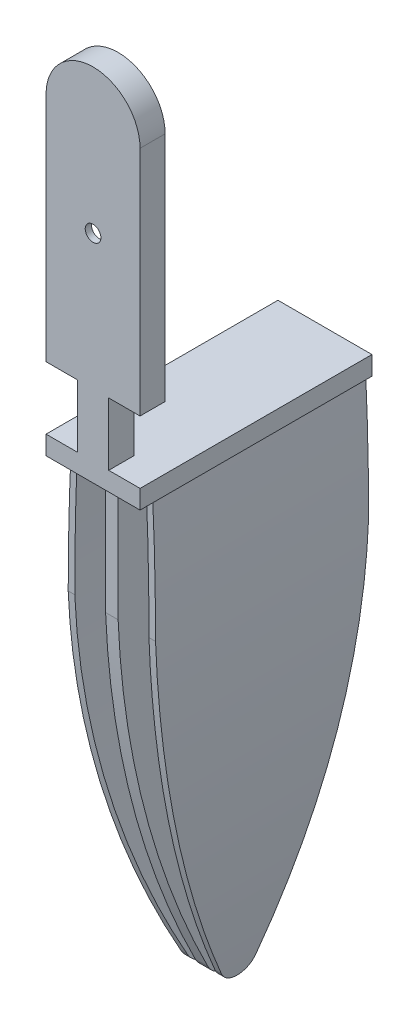
from build123d import *

# Parameters (mm, degrees)
EXTRUDE_1_DEPTH          = 2
EXTRUDE_1_DEPTH_BACK     = 2
EXTRUDE_2_DEPTH          = 7.5
EXTRUDE_2_DEPTH_BACK     = 7.5
SKETCH_6_W               = 37
SKETCH_6_H               = 3
EXTRUDE_4_DEPTH          = 1
EXTRUDE_4_DEPTH_BACK     = 1
FILLET_1_R               = 3
EXTRUDE_8_DEPTH          = 17
EXTRUDE_8_DEPTH_BACK     = 17
CUT_EXTRUDE_3_DEPTH      = 17.5
CUT_EXTRUDE_3_DEPTH_BACK = 17.5
FILLET_7_R               = 3
FILLET_8_R               = 3
FILLET_9_R               = 3
FILLET_10_R              = 3
SKETCH_21_W              = 5
SKETCH_21_H              = 10
CUT_EXTRUDE_4_DEPTH      = 4
CUT_EXTRUDE_5_DEPTH      = 1
CUT_EXTRUDE_5_DEPTH_BACK = 2
SKETCH_23_R              = 1.25
CUT_EXTRUDE_6_DEPTH      = 13


with BuildPart() as part:
    # 草圖1 → 填料-伸長1 (new, two sides: drawn at the far end of the back side and taken through both)
    with BuildSketch(Plane.XY.offset(-EXTRUDE_1_DEPTH_BACK)):
        with BuildLine():
            Line((7.5, 8), (7.5, 55))
            ThreePointArc((7.5, 55), (0, 62.5), (-7.5, 55))
            Line((-7.5, 55), (-7.5, 8))
            Line((-7.5, 8), (7.5, 8))
        make_face()
    extrude(amount=EXTRUDE_1_DEPTH + EXTRUDE_1_DEPTH_BACK)

    # 草圖6 → 填料-伸長2 (add, two sides: drawn at the far end of the back side and taken through both)
    with BuildSketch(Plane(origin=(0, 0, 0), x_dir=(0, 0, -1), z_dir=(1, 0, 0)).offset(-EXTRUDE_2_DEPTH_BACK)):
        with Locations((16.5, 6.5)):
            Rectangle(SKETCH_6_W, SKETCH_6_H)
    extrude(amount=EXTRUDE_2_DEPTH + EXTRUDE_2_DEPTH_BACK)

    # 草圖8 → 填料-伸長4 (add, two sides: drawn at the far end of the back side and taken through both)
    with BuildSketch(Plane(origin=(0, 0, 0), x_dir=(0, 0, -1), z_dir=(1, 0, 0)).offset(-EXTRUDE_4_DEPTH_BACK)):
        with BuildLine():
            Line((1, 5), (35, 5))
            Line((35, 5), (35, -14.904717451))
            ThreePointArc((35, -14.904717451), (30.055498448, -45.958152709), (18, -75))
            ThreePointArc((18, -75), (5.944501552, -45.958152709), (1, -14.904717451))
            Line((1, -14.904717451), (1, 5))
        make_face()
    extrude(amount=EXTRUDE_4_DEPTH + EXTRUDE_4_DEPTH_BACK)

    # 圓角1
    fillet_1_edges = [part.edges().sort_by_distance(p)[0] for p in [
        (0, -75, -18),
    ]]
    fillet(fillet_1_edges, radius=FILLET_1_R)

    # 草圖19 → 填料-伸長8 (add, two sides: drawn at the far end of the back side and taken through both)
    with BuildSketch(Plane.XY.offset(-18).offset(-EXTRUDE_8_DEPTH_BACK)):
        with BuildLine():
            Line((6.5, 5), (5.5, 5))
            ThreePointArc((5.5, 5), (5.47282517, -33.328822067), (2, -71.5))
            Line((2, -71.5), (3, -71.5))
            ThreePointArc((3, -71.5), (6.537897336, -33.331799225), (6.5, 5))
        make_face()
        with BuildLine():
            Line((-3, -71.5), (-2, -71.5))
            ThreePointArc((-2, -71.5), (-5.47282517, -33.328822067), (-5.5, 5))
            Line((-5.5, 5), (-6.5, 5))
            ThreePointArc((-6.5, 5), (-6.537897336, -33.331799225), (-3, -71.5))
        make_face()
    extrude(amount=EXTRUDE_8_DEPTH + EXTRUDE_8_DEPTH_BACK)

    # 草圖20 → 除料-伸長3 (cut, two sides: drawn at the far end of the back side and taken through both)
    with BuildSketch(Plane(origin=(0, 0, 0), x_dir=(0, 0, -1), z_dir=(1, 0, 0)).offset(-CUT_EXTRUDE_3_DEPTH_BACK)):
        with BuildLine():
            Line((1, -14.904717451), (1, -76.940462962))
            Line((1, -76.940462962), (35, -76.940462962))
            Line((35, -76.940462962), (35, -14.904717451))
            ThreePointArc((35, -14.904717451), (30.055498448, -45.958152709), (18, -75))
            ThreePointArc((18, -75), (5.944501552, -45.958152709), (1, -14.904717451))
        make_face()
    extrude(amount=CUT_EXTRUDE_3_DEPTH + CUT_EXTRUDE_3_DEPTH_BACK, mode=Mode.SUBTRACT)

    # 圓角7
    fillet_7_edges = [part.edges().sort_by_distance(p)[0] for p in [
        (2.5, -71.5, -16.104414556),
    ]]
    fillet(fillet_7_edges, radius=FILLET_7_R)

    # 圓角8
    fillet_8_edges = [part.edges().sort_by_distance(p)[0] for p in [
        (2.5, -71.5, -19.895585444),
    ]]
    fillet(fillet_8_edges, radius=FILLET_8_R)

    # 圓角9
    fillet_9_edges = [part.edges().sort_by_distance(p)[0] for p in [
        (-2.5, -71.5, -16.104414556),
    ]]
    fillet(fillet_9_edges, radius=FILLET_9_R)

    # 圓角10
    fillet_10_edges = [part.edges().sort_by_distance(p)[0] for p in [
        (-2.5, -71.5, -19.895585444),
    ]]
    fillet(fillet_10_edges, radius=FILLET_10_R)

    # 草圖21 → 除料-伸長4 (cut)
    with BuildSketch(Plane.XY.offset(2)):
        with Locations((-5, 13)):
            Rectangle(SKETCH_21_W, SKETCH_21_H)
        with Locations((5, 13)):
            Rectangle(SKETCH_21_W, SKETCH_21_H)
    extrude(amount=-CUT_EXTRUDE_4_DEPTH, mode=Mode.SUBTRACT)

    # 草圖3 → 除料-伸長5 (cut, two sides: drawn at the far end of the back side and taken through both)
    with BuildSketch(Plane.XY.offset(-CUT_EXTRUDE_5_DEPTH_BACK)):
        with BuildLine():
            Line((-2.106194146, 57.35480611), (-4.932538983, 40.323847539))
            ThreePointArc((-4.932538983, 40.323847539), (-5, 39.50527611), (-4.932538983, 38.686704682))
            Line((-4.932538983, 38.686704682), (-2.106194146, 21.65574611))
            ThreePointArc((-2.106194146, 21.65574611), (0, 19.87027611), (2.106194146, 21.65574611))
            Line((2.106194146, 21.65574611), (4.932538983, 38.686704682))
            ThreePointArc((4.932538983, 38.686704682), (5, 39.50527611), (4.932538983, 40.323847539))
            Line((4.932538983, 40.323847539), (2.106194146, 57.35480611))
            ThreePointArc((2.106194146, 57.35480611), (0, 59.14027611), (-2.106194146, 57.35480611))
        make_face()
    extrude(amount=CUT_EXTRUDE_5_DEPTH + CUT_EXTRUDE_5_DEPTH_BACK, mode=Mode.SUBTRACT)

    # 草圖23 → 除料-伸長6 (cut)
    with BuildSketch(Plane(origin=(0, 0, -2), x_dir=(-1, 0, 0), z_dir=(0, 0, -1))):
        with Locations((0, 39.50527611)):
            Circle(SKETCH_23_R)
    extrude(amount=-CUT_EXTRUDE_6_DEPTH, mode=Mode.SUBTRACT)


solid = part.part
